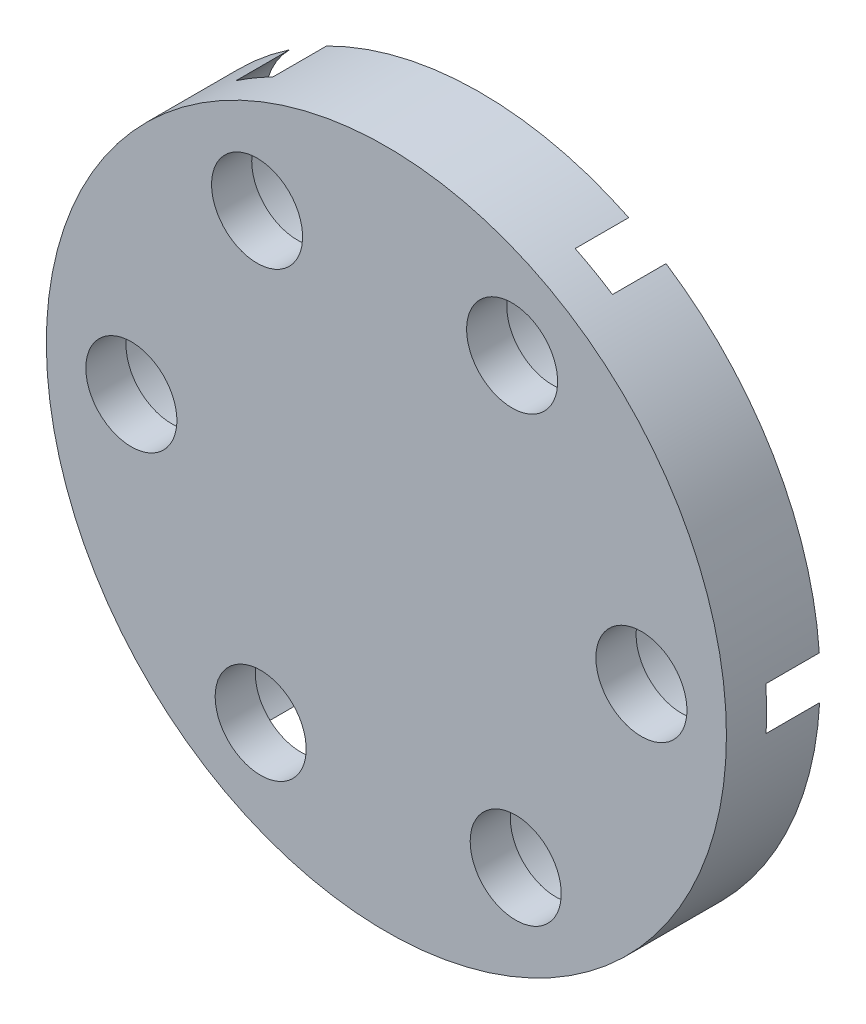
from build123d import *

# Parameters (mm, degrees)
SKETCH1_R                                   = 12.7
BOSS_EXTRUDE1_DEPTH                         = 3.5
CBORE_FOR_M3_CHEESE_HEAD_SCREW1_D           = 3.4
CBORE_FOR_M3_CHEESE_HEAD_SCREW1_CBORE_D     = 6.5
CBORE_FOR_M3_CHEESE_HEAD_SCREW1_CBORE_DEPTH = 2
SKETCH7_R                                   = 6.275
SKETCH7_R_2                                 = 4
BOSS_EXTRUDE2_DEPTH                         = 1
CHAMFER1_SIZE                               = 0.2


with BuildPart() as part:
    # Sketch1 → Boss-Extrude1 (new body)
    with BuildSketch(Plane.XY):
        Circle(SKETCH1_R)
    extrude(amount=BOSS_EXTRUDE1_DEPTH)

    # CBORE for M3 Cheese Head Screw1 (through all)
    with Locations(Plane(origin=(0, 0, 0), x_dir=(-1, 0, 0), z_dir=(0, 0, -1))):
        with Locations((4.694946795, -8.287526748), (-4.8297353, -8.209706568), (-9.524682095, 0.07782018), (-4.694946795, 8.287526748), (4.8297353, 8.209706568), (9.524682095, -0.07782018)):
            CounterBoreHole(CBORE_FOR_M3_CHEESE_HEAD_SCREW1_D / 2, CBORE_FOR_M3_CHEESE_HEAD_SCREW1_CBORE_D / 2, CBORE_FOR_M3_CHEESE_HEAD_SCREW1_CBORE_DEPTH)

    # Sketch7 → Boss-Extrude2 (add)
    with BuildSketch(Plane(origin=(0, 0, 0), x_dir=(-1, 0, 0), z_dir=(0, 0, -1))):
        Circle(SKETCH7_R)
        Circle(SKETCH7_R_2, mode=Mode.SUBTRACT)
    extrude(amount=BOSS_EXTRUDE2_DEPTH)

    # Chamfer1
    chamfer1_edges = [part.edges().sort_by_distance(p)[0] for p in [
        (4, 0, -1),
    ]]
    chamfer(chamfer1_edges, length=CHAMFER1_SIZE)


solid = part.part
